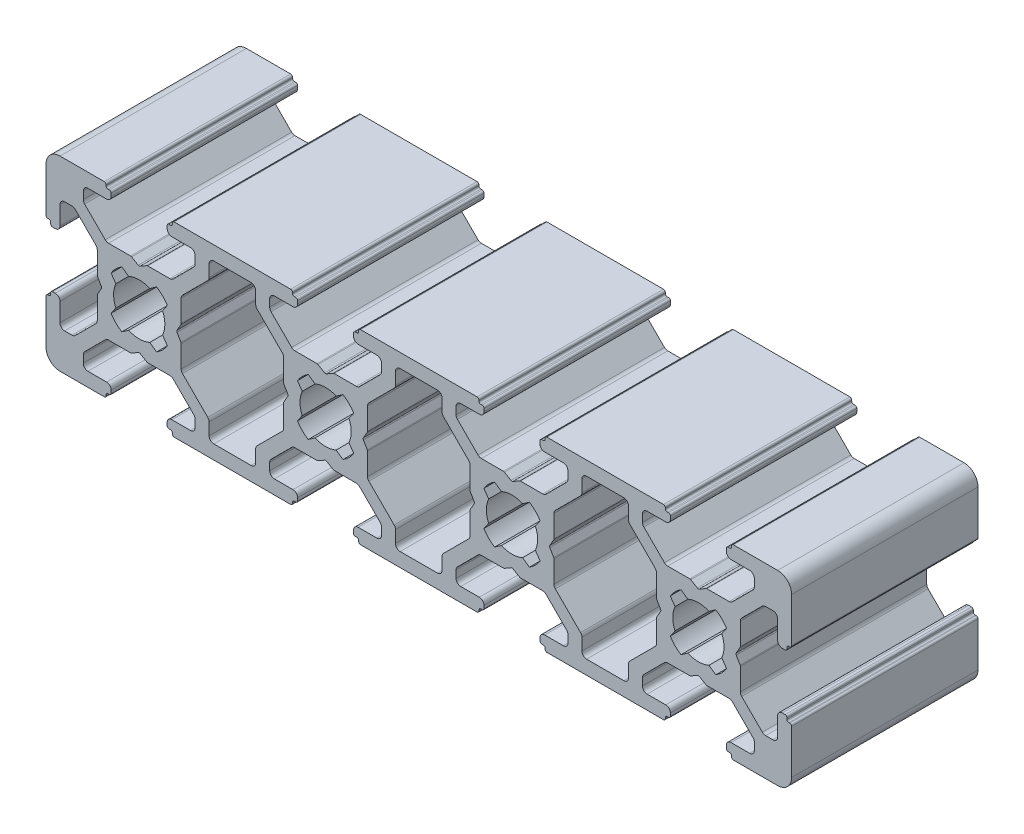
from build123d import *

# Parameters (mm, degrees)
EXTRUDE_1_DEPTH = 20


with BuildPart() as part:
    # Эскиз1 → Бобышка-Вытянуть1 (new body)
    with BuildSketch(Plane.XY):
        with BuildLine():
            Line((-13.645430713, 4.646446609), (-15.853553391, 6.854569287))
            ThreePointArc((-15.853553391, 6.854569287), (-15.961939766, 7.016780961), (-16, 7.208122677))
            Line((-16, 7.208122677), (-16, 8))
            ThreePointArc((-16, 8), (-15.853553391, 8.353553391), (-15.5, 8.5))
            Line((-15.5, 8.5), (-13.5, 8.5))
            ThreePointArc((-13.5, 8.5), (-13.146446609, 8.646446609), (-13, 9))
            Line((-13, 9), (-13, 9.3))
            ThreePointArc((-13, 9.3), (-13.058578644, 9.441421356), (-13.2, 9.5))
            Line((-13.2, 9.5), (-13.35, 9.5))
            ThreePointArc((-13.35, 9.5), (-13.491421356, 9.558578644), (-13.55, 9.7))
            Line((-13.55, 9.7), (-13.55, 9.8))
            ThreePointArc((-13.55, 9.8), (-13.608578644, 9.941421356), (-13.75, 10))
            Line((-13.75, 10), (-18.5, 10))
            ThreePointArc((-18.5, 10), (-19.560660172, 9.560660172), (-20, 8.5))
            Line((-20, 8.5), (-20, 3.75))
            ThreePointArc((-20, 3.75), (-19.941421356, 3.608578644), (-19.8, 3.55))
            Line((-19.8, 3.55), (-19.7, 3.55))
            ThreePointArc((-19.7, 3.55), (-19.558578644, 3.491421356), (-19.5, 3.35))
            Line((-19.5, 3.35), (-19.5, 3.2))
            ThreePointArc((-19.5, 3.2), (-19.441421356, 3.058578644), (-19.3, 3))
            Line((-19.3, 3), (-19, 3))
            ThreePointArc((-19, 3), (-18.646446609, 3.146446609), (-18.5, 3.5))
            Line((-18.5, 3.5), (-18.5, 5.5))
            ThreePointArc((-18.5, 5.5), (-18.353553391, 5.853553391), (-18, 6))
            Line((-18, 6), (-17.208122677, 6))
            ThreePointArc((-17.208122677, 6), (-17.016780961, 5.961939766), (-16.854569287, 5.853553391))
            Line((-16.854569287, 5.853553391), (-14.646446609, 3.645430713))
            ThreePointArc((-14.646446609, 3.645430713), (-14.538060234, 3.483219039), (-14.5, 3.291877323))
            Line((-14.5, 3.291877323), (-14.5, 0.919615242))
            ThreePointArc((-14.5, 0.919615242), (-14.493185165, 0.867851433), (-14.473205081, 0.819615242))
            Line((-14.473205081, 0.819615242), (-14.057735027, 0.1))
            ThreePointArc((-14.057735027, 0.1), (-14.030940108, 0), (-14.057735027, -0.1))
            Line((-14.057735027, -0.1), (-14.473205081, -0.819615242))
            ThreePointArc((-14.473205081, -0.819615242), (-14.493185165, -0.867851433), (-14.5, -0.919615242))
            Line((-14.5, -0.919615242), (-14.5, -3.291877323))
            ThreePointArc((-14.5, -3.291877323), (-14.538060234, -3.483219039), (-14.646446609, -3.645430713))
            Line((-14.646446609, -3.645430713), (-16.854569287, -5.853553391))
            ThreePointArc((-16.854569287, -5.853553391), (-17.016780961, -5.961939766), (-17.208122677, -6))
            Line((-17.208122677, -6), (-18, -6))
            ThreePointArc((-18, -6), (-18.353553391, -5.853553391), (-18.5, -5.5))
            Line((-18.5, -5.5), (-18.5, -3.5))
            ThreePointArc((-18.5, -3.5), (-18.646446609, -3.146446609), (-19, -3))
            Line((-19, -3), (-19.3, -3))
            ThreePointArc((-19.3, -3), (-19.441421356, -3.058578644), (-19.5, -3.2))
            Line((-19.5, -3.2), (-19.5, -3.35))
            ThreePointArc((-19.5, -3.35), (-19.558578644, -3.491421356), (-19.7, -3.55))
            Line((-19.7, -3.55), (-19.8, -3.55))
            ThreePointArc((-19.8, -3.55), (-19.941421356, -3.608578644), (-20, -3.75))
            Line((-20, -3.75), (-20, -8.5))
            ThreePointArc((-20, -8.5), (-19.560660172, -9.560660172), (-18.5, -10))
            Line((-18.5, -10), (-13.75, -10))
            ThreePointArc((-13.75, -10), (-13.608578644, -9.941421356), (-13.55, -9.8))
            Line((-13.55, -9.8), (-13.55, -9.7))
            ThreePointArc((-13.55, -9.7), (-13.491421356, -9.558578644), (-13.35, -9.5))
            Line((-13.35, -9.5), (-13.2, -9.5))
            ThreePointArc((-13.2, -9.5), (-13.058578644, -9.441421356), (-13, -9.3))
            Line((-13, -9.3), (-13, -9))
            ThreePointArc((-13, -9), (-13.146446609, -8.646446609), (-13.5, -8.5))
            Line((-13.5, -8.5), (-15.5, -8.5))
            ThreePointArc((-15.5, -8.5), (-15.853553391, -8.353553391), (-16, -8))
            Line((-16, -8), (-16, -7.208122677))
            ThreePointArc((-16, -7.208122677), (-15.961939766, -7.016780961), (-15.853553391, -6.854569287))
            Line((-15.853553391, -6.854569287), (-13.645430713, -4.646446609))
            ThreePointArc((-13.645430713, -4.646446609), (-13.483219039, -4.538060234), (-13.291877323, -4.5))
            Line((-13.291877323, -4.5), (-10.919615242, -4.5))
            ThreePointArc((-10.919615242, -4.5), (-10.867851433, -4.493185165), (-10.819615242, -4.473205081))
            Line((-10.819615242, -4.473205081), (-10.1, -4.057735027))
            ThreePointArc((-10.1, -4.057735027), (-10, -4.030940108), (-9.9, -4.057735027))
            Line((-9.9, -4.057735027), (-9.180384758, -4.473205081))
            ThreePointArc((-9.180384758, -4.473205081), (-9.132148567, -4.493185165), (-9.080384758, -4.5))
            Line((-9.080384758, -4.5), (-6.708122677, -4.5))
            ThreePointArc((-6.708122677, -4.5), (-6.516780961, -4.538060234), (-6.354569287, -4.646446609))
            Line((-6.354569287, -4.646446609), (-4.146446609, -6.854569287))
            ThreePointArc((-4.146446609, -6.854569287), (-4.038060234, -7.016780961), (-4, -7.208122677))
            Line((-4, -7.208122677), (-4, -8))
            ThreePointArc((-4, -8), (-4.146446609, -8.353553391), (-4.5, -8.5))
            Line((-4.5, -8.5), (-6.5, -8.5))
            ThreePointArc((-6.5, -8.5), (-6.853553391, -8.646446609), (-7, -9))
            Line((-7, -9), (-7, -9.3))
            ThreePointArc((-7, -9.3), (-6.941421356, -9.441421356), (-6.8, -9.5))
            Line((-6.8, -9.5), (-6.65, -9.5))
            ThreePointArc((-6.65, -9.5), (-6.508578644, -9.558578644), (-6.45, -9.7))
            Line((-6.45, -9.7), (-6.45, -9.8))
            ThreePointArc((-6.45, -9.8), (-6.391421356, -9.941421356), (-6.25, -10))
            Line((-6.25, -10), (6.25, -10))
            ThreePointArc((6.25, -10), (6.391421356, -9.941421356), (6.45, -9.8))
            Line((6.45, -9.8), (6.45, -9.7))
            ThreePointArc((6.45, -9.7), (6.508578644, -9.558578644), (6.65, -9.5))
            Line((6.65, -9.5), (6.8, -9.5))
            ThreePointArc((6.8, -9.5), (6.941421356, -9.441421356), (7, -9.3))
            Line((7, -9.3), (7, -9))
            ThreePointArc((7, -9), (6.853553391, -8.646446609), (6.5, -8.5))
            Line((6.5, -8.5), (4.5, -8.5))
            ThreePointArc((4.5, -8.5), (4.146446609, -8.353553391), (4, -8))
            Line((4, -8), (4, -7.208122677))
            ThreePointArc((4, -7.208122677), (4.038060234, -7.016780961), (4.146446609, -6.854569287))
            Line((4.146446609, -6.854569287), (6.354569287, -4.646446609))
            ThreePointArc((6.354569287, -4.646446609), (6.516780961, -4.538060234), (6.708122677, -4.5))
            Line((6.708122677, -4.5), (9.080384758, -4.5))
            ThreePointArc((9.080384758, -4.5), (9.132148567, -4.493185165), (9.180384758, -4.473205081))
            Line((9.180384758, -4.473205081), (9.9, -4.057735027))
            ThreePointArc((9.9, -4.057735027), (10, -4.030940108), (10.1, -4.057735027))
            Line((10.1, -4.057735027), (10.819615242, -4.473205081))
            ThreePointArc((10.819615242, -4.473205081), (10.867851433, -4.493185165), (10.919615242, -4.5))
            Line((10.919615242, -4.5), (13.291877323, -4.5))
            ThreePointArc((13.291877323, -4.5), (13.483219039, -4.538060234), (13.645430713, -4.646446609))
            Line((13.645430713, -4.646446609), (15.853553391, -6.854569287))
            ThreePointArc((15.853553391, -6.854569287), (15.961939766, -7.016780961), (16, -7.208122677))
            Line((16, -7.208122677), (16, -8))
            ThreePointArc((16, -8), (15.853553391, -8.353553391), (15.5, -8.5))
            Line((15.5, -8.5), (13.5, -8.5))
            ThreePointArc((13.5, -8.5), (13.146446609, -8.646446609), (13, -9))
            Line((13, -9), (13, -9.3))
            ThreePointArc((13, -9.3), (13.058578644, -9.441421356), (13.2, -9.5))
            Line((13.2, -9.5), (13.35, -9.5))
            ThreePointArc((13.35, -9.5), (13.491421356, -9.558578644), (13.55, -9.7))
            Line((13.55, -9.7), (13.55, -9.8))
            ThreePointArc((13.55, -9.8), (13.608578644, -9.941421356), (13.75, -10))
            Line((13.75, -10), (26.25, -10))
            ThreePointArc((26.25, -10), (26.391421356, -9.941421356), (26.45, -9.8))
            Line((26.45, -9.8), (26.45, -9.7))
            ThreePointArc((26.45, -9.7), (26.508578644, -9.558578644), (26.65, -9.5))
            Line((26.65, -9.5), (26.8, -9.5))
            ThreePointArc((26.8, -9.5), (26.941421356, -9.441421356), (27, -9.3))
            Line((27, -9.3), (27, -9))
            ThreePointArc((27, -9), (26.853553391, -8.646446609), (26.5, -8.5))
            Line((26.5, -8.5), (24.5, -8.5))
            ThreePointArc((24.5, -8.5), (24.146446609, -8.353553391), (24, -8))
            Line((24, -8), (24, -7.208122677))
            ThreePointArc((24, -7.208122677), (24.038060234, -7.016780961), (24.146446609, -6.854569287))
            Line((24.146446609, -6.854569287), (26.354569287, -4.646446609))
            ThreePointArc((26.354569287, -4.646446609), (26.516780961, -4.538060234), (26.708122677, -4.5))
            Line((26.708122677, -4.5), (29.080384758, -4.5))
            ThreePointArc((29.080384758, -4.5), (29.132148567, -4.493185165), (29.180384758, -4.473205081))
            Line((29.180384758, -4.473205081), (29.9, -4.057735027))
            ThreePointArc((29.9, -4.057735027), (30, -4.030940108), (30.1, -4.057735027))
            Line((30.1, -4.057735027), (30.819615242, -4.473205081))
            ThreePointArc((30.819615242, -4.473205081), (30.867851433, -4.493185165), (30.919615242, -4.5))
            Line((30.919615242, -4.5), (33.291877323, -4.5))
            ThreePointArc((33.291877323, -4.5), (33.483219039, -4.538060234), (33.645430713, -4.646446609))
            Line((33.645430713, -4.646446609), (35.853553391, -6.854569287))
            ThreePointArc((35.853553391, -6.854569287), (35.961939766, -7.016780961), (36, -7.208122677))
            Line((36, -7.208122677), (36, -8))
            ThreePointArc((36, -8), (35.853553391, -8.353553391), (35.5, -8.5))
            Line((35.5, -8.5), (33.5, -8.5))
            ThreePointArc((33.5, -8.5), (33.146446609, -8.646446609), (33, -9))
            Line((33, -9), (33, -9.3))
            ThreePointArc((33, -9.3), (33.058578644, -9.441421356), (33.2, -9.5))
            Line((33.2, -9.5), (33.35, -9.5))
            ThreePointArc((33.35, -9.5), (33.491421356, -9.558578644), (33.55, -9.7))
            Line((33.55, -9.7), (33.55, -9.8))
            ThreePointArc((33.55, -9.8), (33.608578644, -9.941421356), (33.75, -10))
            Line((33.75, -10), (46.25, -10))
            ThreePointArc((46.25, -10), (46.391421356, -9.941421356), (46.45, -9.8))
            Line((46.45, -9.8), (46.45, -9.7))
            ThreePointArc((46.45, -9.7), (46.508578644, -9.558578644), (46.65, -9.5))
            Line((46.65, -9.5), (46.8, -9.5))
            ThreePointArc((46.8, -9.5), (46.941421356, -9.441421356), (47, -9.3))
            Line((47, -9.3), (47, -9))
            ThreePointArc((47, -9), (46.853553391, -8.646446609), (46.5, -8.5))
            Line((46.5, -8.5), (44.5, -8.5))
            ThreePointArc((44.5, -8.5), (44.146446609, -8.353553391), (44, -8))
            Line((44, -8), (44, -7.208122677))
            ThreePointArc((44, -7.208122677), (44.038060234, -7.016780961), (44.146446609, -6.854569287))
            Line((44.146446609, -6.854569287), (46.354569287, -4.646446609))
            ThreePointArc((46.354569287, -4.646446609), (46.516780961, -4.538060234), (46.708122677, -4.5))
            Line((46.708122677, -4.5), (49.080384758, -4.5))
            ThreePointArc((49.080384758, -4.5), (49.132148567, -4.493185165), (49.180384758, -4.473205081))
            Line((49.180384758, -4.473205081), (49.9, -4.057735027))
            ThreePointArc((49.9, -4.057735027), (50, -4.030940108), (50.1, -4.057735027))
            Line((50.1, -4.057735027), (50.819615242, -4.473205081))
            ThreePointArc((50.819615242, -4.473205081), (50.867851433, -4.493185165), (50.919615242, -4.5))
            Line((50.919615242, -4.5), (53.291877323, -4.5))
            ThreePointArc((53.291877323, -4.5), (53.483219039, -4.538060234), (53.645430713, -4.646446609))
            Line((53.645430713, -4.646446609), (55.853553391, -6.854569287))
            ThreePointArc((55.853553391, -6.854569287), (55.961939766, -7.016780961), (56, -7.208122677))
            Line((56, -7.208122677), (56, -8))
            ThreePointArc((56, -8), (55.853553391, -8.353553391), (55.5, -8.5))
            Line((55.5, -8.5), (53.5, -8.5))
            ThreePointArc((53.5, -8.5), (53.146446609, -8.646446609), (53, -9))
            Line((53, -9), (53, -9.3))
            ThreePointArc((53, -9.3), (53.058578644, -9.441421356), (53.2, -9.5))
            Line((53.2, -9.5), (53.35, -9.5))
            ThreePointArc((53.35, -9.5), (53.491421356, -9.558578644), (53.55, -9.7))
            Line((53.55, -9.7), (53.55, -9.8))
            ThreePointArc((53.55, -9.8), (53.608578644, -9.941421356), (53.75, -10))
            Line((53.75, -10), (58.5, -10))
            ThreePointArc((58.5, -10), (59.560660172, -9.560660172), (60, -8.5))
            Line((60, -8.5), (60, -3.75))
            ThreePointArc((60, -3.75), (59.941421356, -3.608578644), (59.8, -3.55))
            Line((59.8, -3.55), (59.7, -3.55))
            ThreePointArc((59.7, -3.55), (59.558578644, -3.491421356), (59.5, -3.35))
            Line((59.5, -3.35), (59.5, -3.2))
            ThreePointArc((59.5, -3.2), (59.441421356, -3.058578644), (59.3, -3))
            Line((59.3, -3), (59, -3))
            ThreePointArc((59, -3), (58.646446609, -3.146446609), (58.5, -3.5))
            Line((58.5, -3.5), (58.5, -5.5))
            ThreePointArc((58.5, -5.5), (58.353553391, -5.853553391), (58, -6))
            Line((58, -6), (57.208122677, -6))
            ThreePointArc((57.208122677, -6), (57.016780961, -5.961939766), (56.854569287, -5.853553391))
            Line((56.854569287, -5.853553391), (54.646446609, -3.645430713))
            ThreePointArc((54.646446609, -3.645430713), (54.538060234, -3.483219039), (54.5, -3.291877323))
            Line((54.5, -3.291877323), (54.5, -0.919615242))
            ThreePointArc((54.5, -0.919615242), (54.493185165, -0.867851433), (54.473205081, -0.819615242))
            Line((54.473205081, -0.819615242), (54.057735027, -0.1))
            ThreePointArc((54.057735027, -0.1), (54.030940108, 0), (54.057735027, 0.1))
            Line((54.057735027, 0.1), (54.473205081, 0.819615242))
            ThreePointArc((54.473205081, 0.819615242), (54.493185165, 0.867851433), (54.5, 0.919615242))
            Line((54.5, 0.919615242), (54.5, 3.291877323))
            ThreePointArc((54.5, 3.291877323), (54.538060234, 3.483219039), (54.646446609, 3.645430713))
            Line((54.646446609, 3.645430713), (56.854569287, 5.853553391))
            ThreePointArc((56.854569287, 5.853553391), (57.016780961, 5.961939766), (57.208122677, 6))
            Line((57.208122677, 6), (58, 6))
            ThreePointArc((58, 6), (58.353553391, 5.853553391), (58.5, 5.5))
            Line((58.5, 5.5), (58.5, 3.5))
            ThreePointArc((58.5, 3.5), (58.646446609, 3.146446609), (59, 3))
            Line((59, 3), (59.3, 3))
            ThreePointArc((59.3, 3), (59.441421356, 3.058578644), (59.5, 3.2))
            Line((59.5, 3.2), (59.5, 3.35))
            ThreePointArc((59.5, 3.35), (59.558578644, 3.491421356), (59.7, 3.55))
            Line((59.7, 3.55), (59.8, 3.55))
            ThreePointArc((59.8, 3.55), (59.941421356, 3.608578644), (60, 3.75))
            Line((60, 3.75), (60, 8.5))
            ThreePointArc((60, 8.5), (59.560660172, 9.560660172), (58.5, 10))
            Line((58.5, 10), (53.75, 10))
            ThreePointArc((53.75, 10), (53.608578644, 9.941421356), (53.55, 9.8))
            Line((53.55, 9.8), (53.55, 9.7))
            ThreePointArc((53.55, 9.7), (53.491421356, 9.558578644), (53.35, 9.5))
            Line((53.35, 9.5), (53.2, 9.5))
            ThreePointArc((53.2, 9.5), (53.058578644, 9.441421356), (53, 9.3))
            Line((53, 9.3), (53, 9))
            ThreePointArc((53, 9), (53.146446609, 8.646446609), (53.5, 8.5))
            Line((53.5, 8.5), (55.5, 8.5))
            ThreePointArc((55.5, 8.5), (55.853553391, 8.353553391), (56, 8))
            Line((56, 8), (56, 7.208122677))
            ThreePointArc((56, 7.208122677), (55.961939766, 7.016780961), (55.853553391, 6.854569287))
            Line((55.853553391, 6.854569287), (53.645430713, 4.646446609))
            ThreePointArc((53.645430713, 4.646446609), (53.483219039, 4.538060234), (53.291877323, 4.5))
            Line((53.291877323, 4.5), (50.919615242, 4.5))
            ThreePointArc((50.919615242, 4.5), (50.867851433, 4.493185165), (50.819615242, 4.473205081))
            Line((50.819615242, 4.473205081), (50.1, 4.057735027))
            ThreePointArc((50.1, 4.057735027), (50, 4.030940108), (49.9, 4.057735027))
            Line((49.9, 4.057735027), (49.180384758, 4.473205081))
            ThreePointArc((49.180384758, 4.473205081), (49.132148567, 4.493185165), (49.080384758, 4.5))
            Line((49.080384758, 4.5), (46.708122677, 4.5))
            ThreePointArc((46.708122677, 4.5), (46.516780961, 4.538060234), (46.354569287, 4.646446609))
            Line((46.354569287, 4.646446609), (44.146446609, 6.854569287))
            ThreePointArc((44.146446609, 6.854569287), (44.038060234, 7.016780961), (44, 7.208122677))
            Line((44, 7.208122677), (44, 8))
            ThreePointArc((44, 8), (44.146446609, 8.353553391), (44.5, 8.5))
            Line((44.5, 8.5), (46.5, 8.5))
            ThreePointArc((46.5, 8.5), (46.853553391, 8.646446609), (47, 9))
            Line((47, 9), (47, 9.3))
            ThreePointArc((47, 9.3), (46.941421356, 9.441421356), (46.8, 9.5))
            Line((46.8, 9.5), (46.65, 9.5))
            ThreePointArc((46.65, 9.5), (46.508578644, 9.558578644), (46.45, 9.7))
            Line((46.45, 9.7), (46.45, 9.8))
            ThreePointArc((46.45, 9.8), (46.391421356, 9.941421356), (46.25, 10))
            Line((46.25, 10), (33.75, 10))
            ThreePointArc((33.75, 10), (33.608578644, 9.941421356), (33.55, 9.8))
            Line((33.55, 9.8), (33.55, 9.7))
            ThreePointArc((33.55, 9.7), (33.491421356, 9.558578644), (33.35, 9.5))
            Line((33.35, 9.5), (33.2, 9.5))
            ThreePointArc((33.2, 9.5), (33.058578644, 9.441421356), (33, 9.3))
            Line((33, 9.3), (33, 9))
            ThreePointArc((33, 9), (33.146446609, 8.646446609), (33.5, 8.5))
            Line((33.5, 8.5), (35.5, 8.5))
            ThreePointArc((35.5, 8.5), (35.853553391, 8.353553391), (36, 8))
            Line((36, 8), (36, 7.208122677))
            ThreePointArc((36, 7.208122677), (35.961939766, 7.016780961), (35.853553391, 6.854569287))
            Line((35.853553391, 6.854569287), (33.645430713, 4.646446609))
            ThreePointArc((33.645430713, 4.646446609), (33.483219039, 4.538060234), (33.291877323, 4.5))
            Line((33.291877323, 4.5), (30.919615242, 4.5))
            ThreePointArc((30.919615242, 4.5), (30.867851433, 4.493185165), (30.819615242, 4.473205081))
            Line((30.819615242, 4.473205081), (30.1, 4.057735027))
            ThreePointArc((30.1, 4.057735027), (30, 4.030940108), (29.9, 4.057735027))
            Line((29.9, 4.057735027), (29.180384758, 4.473205081))
            ThreePointArc((29.180384758, 4.473205081), (29.132148567, 4.493185165), (29.080384758, 4.5))
            Line((29.080384758, 4.5), (26.708122677, 4.5))
            ThreePointArc((26.708122677, 4.5), (26.516780961, 4.538060234), (26.354569287, 4.646446609))
            Line((26.354569287, 4.646446609), (24.146446609, 6.854569287))
            ThreePointArc((24.146446609, 6.854569287), (24.038060234, 7.016780961), (24, 7.208122677))
            Line((24, 7.208122677), (24, 8))
            ThreePointArc((24, 8), (24.146446609, 8.353553391), (24.5, 8.5))
            Line((24.5, 8.5), (26.5, 8.5))
            ThreePointArc((26.5, 8.5), (26.853553391, 8.646446609), (27, 9))
            Line((27, 9), (27, 9.3))
            ThreePointArc((27, 9.3), (26.941421356, 9.441421356), (26.8, 9.5))
            Line((26.8, 9.5), (26.65, 9.5))
            ThreePointArc((26.65, 9.5), (26.508578644, 9.558578644), (26.45, 9.7))
            Line((26.45, 9.7), (26.45, 9.8))
            ThreePointArc((26.45, 9.8), (26.391421356, 9.941421356), (26.25, 10))
            Line((26.25, 10), (13.75, 10))
            ThreePointArc((13.75, 10), (13.608578644, 9.941421356), (13.55, 9.8))
            Line((13.55, 9.8), (13.55, 9.7))
            ThreePointArc((13.55, 9.7), (13.491421356, 9.558578644), (13.35, 9.5))
            Line((13.35, 9.5), (13.2, 9.5))
            ThreePointArc((13.2, 9.5), (13.058578644, 9.441421356), (13, 9.3))
            Line((13, 9.3), (13, 9))
            ThreePointArc((13, 9), (13.146446609, 8.646446609), (13.5, 8.5))
            Line((13.5, 8.5), (15.5, 8.5))
            ThreePointArc((15.5, 8.5), (15.853553391, 8.353553391), (16, 8))
            Line((16, 8), (16, 7.208122677))
            ThreePointArc((16, 7.208122677), (15.961939766, 7.016780961), (15.853553391, 6.854569287))
            Line((15.853553391, 6.854569287), (13.645430713, 4.646446609))
            ThreePointArc((13.645430713, 4.646446609), (13.483219039, 4.538060234), (13.291877323, 4.5))
            Line((13.291877323, 4.5), (10.919615242, 4.5))
            ThreePointArc((10.919615242, 4.5), (10.867851433, 4.493185165), (10.819615242, 4.473205081))
            Line((10.819615242, 4.473205081), (10.1, 4.057735027))
            ThreePointArc((10.1, 4.057735027), (10, 4.030940108), (9.9, 4.057735027))
            Line((9.9, 4.057735027), (9.180384758, 4.473205081))
            ThreePointArc((9.180384758, 4.473205081), (9.132148567, 4.493185165), (9.080384758, 4.5))
            Line((9.080384758, 4.5), (6.708122677, 4.5))
            ThreePointArc((6.708122677, 4.5), (6.516780961, 4.538060234), (6.354569287, 4.646446609))
            Line((6.354569287, 4.646446609), (4.146446609, 6.854569287))
            ThreePointArc((4.146446609, 6.854569287), (4.038060234, 7.016780961), (4, 7.208122677))
            Line((4, 7.208122677), (4, 8))
            ThreePointArc((4, 8), (4.146446609, 8.353553391), (4.5, 8.5))
            Line((4.5, 8.5), (6.5, 8.5))
            ThreePointArc((6.5, 8.5), (6.853553391, 8.646446609), (7, 9))
            Line((7, 9), (7, 9.3))
            ThreePointArc((7, 9.3), (6.941421356, 9.441421356), (6.8, 9.5))
            Line((6.8, 9.5), (6.65, 9.5))
            ThreePointArc((6.65, 9.5), (6.508578644, 9.558578644), (6.45, 9.7))
            Line((6.45, 9.7), (6.45, 9.8))
            ThreePointArc((6.45, 9.8), (6.391421356, 9.941421356), (6.25, 10))
            Line((6.25, 10), (-6.25, 10))
            ThreePointArc((-6.25, 10), (-6.391421356, 9.941421356), (-6.45, 9.8))
            Line((-6.45, 9.8), (-6.45, 9.7))
            ThreePointArc((-6.45, 9.7), (-6.508578644, 9.558578644), (-6.65, 9.5))
            Line((-6.65, 9.5), (-6.8, 9.5))
            ThreePointArc((-6.8, 9.5), (-6.941421356, 9.441421356), (-7, 9.3))
            Line((-7, 9.3), (-7, 9))
            ThreePointArc((-7, 9), (-6.853553391, 8.646446609), (-6.5, 8.5))
            Line((-6.5, 8.5), (-4.5, 8.5))
            ThreePointArc((-4.5, 8.5), (-4.146446609, 8.353553391), (-4, 8))
            Line((-4, 8), (-4, 7.208122677))
            ThreePointArc((-4, 7.208122677), (-4.038060234, 7.016780961), (-4.146446609, 6.854569287))
            Line((-4.146446609, 6.854569287), (-6.354569287, 4.646446609))
            ThreePointArc((-6.354569287, 4.646446609), (-6.516780961, 4.538060234), (-6.708122677, 4.5))
            Line((-6.708122677, 4.5), (-9.080384758, 4.5))
            ThreePointArc((-9.080384758, 4.5), (-9.132148567, 4.493185165), (-9.180384758, 4.473205081))
            Line((-9.180384758, 4.473205081), (-9.9, 4.057735027))
            ThreePointArc((-9.9, 4.057735027), (-10, 4.030940108), (-10.1, 4.057735027))
            Line((-10.1, 4.057735027), (-10.819615242, 4.473205081))
            ThreePointArc((-10.819615242, 4.473205081), (-10.867851433, 4.493185165), (-10.919615242, 4.5))
            Line((-10.919615242, 4.5), (-13.291877323, 4.5))
            ThreePointArc((-13.291877323, 4.5), (-13.483219039, 4.538060234), (-13.645430713, 4.646446609))
        make_face()
        with BuildLine():
            Line((3.145430713, -5.853553391), (2.646446609, -6.352537495))
            ThreePointArc((2.646446609, -6.352537495), (2.538060234, -6.514749169), (2.5, -6.706090885))
            Line((2.5, -6.706090885), (2.5, -8))
            ThreePointArc((2.5, -8), (2.353553391, -8.353553391), (2, -8.5))
            Line((2, -8.5), (-2, -8.5))
            ThreePointArc((-2, -8.5), (-2.353553391, -8.353553391), (-2.5, -8))
            Line((-2.5, -8), (-2.5, -6.706090885))
            ThreePointArc((-2.5, -6.706090885), (-2.538060234, -6.514749169), (-2.646446609, -6.352537495))
            Line((-2.646446609, -6.352537495), (-3.145430713, -5.853553391))
            Line((-3.145430713, -5.853553391), (-5.353553391, -3.645430713))
            ThreePointArc((-5.353553391, -3.645430713), (-5.461939766, -3.483219039), (-5.5, -3.291877323))
            Line((-5.5, -3.291877323), (-5.5, -0.919615242))
            ThreePointArc((-5.5, -0.919615242), (-5.506814835, -0.867851433), (-5.526794919, -0.819615242))
            Line((-5.526794919, -0.819615242), (-5.942264973, -0.1))
            ThreePointArc((-5.942264973, -0.1), (-5.969059892, 0), (-5.942264973, 0.1))
            Line((-5.942264973, 0.1), (-5.526794919, 0.819615242))
            ThreePointArc((-5.526794919, 0.819615242), (-5.506814835, 0.867851433), (-5.5, 0.919615242))
            Line((-5.5, 0.919615242), (-5.5, 3.291877323))
            ThreePointArc((-5.5, 3.291877323), (-5.461939766, 3.483219039), (-5.353553391, 3.645430713))
            Line((-5.353553391, 3.645430713), (-3.145430713, 5.853553391))
            Line((-3.145430713, 5.853553391), (-2.646446609, 6.352537495))
            ThreePointArc((-2.646446609, 6.352537495), (-2.538060234, 6.514749169), (-2.5, 6.706090885))
            Line((-2.5, 6.706090885), (-2.5, 8))
            ThreePointArc((-2.5, 8), (-2.353553391, 8.353553391), (-2, 8.5))
            Line((-2, 8.5), (2, 8.5))
            ThreePointArc((2, 8.5), (2.353553391, 8.353553391), (2.5, 8))
            Line((2.5, 8), (2.5, 6.706090885))
            ThreePointArc((2.5, 6.706090885), (2.538060234, 6.514749169), (2.646446609, 6.352537495))
            Line((2.646446609, 6.352537495), (3.145430713, 5.853553391))
            Line((3.145430713, 5.853553391), (5.353553391, 3.645430713))
            ThreePointArc((5.353553391, 3.645430713), (5.461939766, 3.483219039), (5.5, 3.291877323))
            Line((5.5, 3.291877323), (5.5, 0.919615242))
            ThreePointArc((5.5, 0.919615242), (5.506814835, 0.867851433), (5.526794919, 0.819615242))
            Line((5.526794919, 0.819615242), (5.942264973, 0.1))
            ThreePointArc((5.942264973, 0.1), (5.969059892, 0), (5.942264973, -0.1))
            Line((5.942264973, -0.1), (5.526794919, -0.819615242))
            ThreePointArc((5.526794919, -0.819615242), (5.506814835, -0.867851433), (5.5, -0.919615242))
            Line((5.5, -0.919615242), (5.5, -3.291877323))
            ThreePointArc((5.5, -3.291877323), (5.461939766, -3.483219039), (5.353553391, -3.645430713))
            Line((5.353553391, -3.645430713), (3.145430713, -5.853553391))
        make_face(mode=Mode.SUBTRACT)
        with BuildLine():
            Line((-13.020442772, 1.865321812), (-12.506504586, 1.131342017))
            ThreePointArc((-12.506504586, 1.131342017), (-12.75, 0), (-12.506504586, -1.131342017))
            Line((-12.506504586, -1.131342017), (-13.020442772, -1.865321812))
            ThreePointArc((-13.020442772, -1.865321812), (-12.510229073, -2.510229073), (-11.865321812, -3.020442772))
            Line((-11.865321812, -3.020442772), (-11.131342017, -2.506504586))
            ThreePointArc((-11.131342017, -2.506504586), (-10, -2.75), (-8.868657983, -2.506504586))
            Line((-8.868657983, -2.506504586), (-8.134678188, -3.020442772))
            ThreePointArc((-8.134678188, -3.020442772), (-7.489770927, -2.510229073), (-6.979557228, -1.865321812))
            Line((-6.979557228, -1.865321812), (-7.493495414, -1.131342017))
            ThreePointArc((-7.493495414, -1.131342017), (-7.25, 0), (-7.493495414, 1.131342017))
            Line((-7.493495414, 1.131342017), (-6.979557228, 1.865321812))
            ThreePointArc((-6.979557228, 1.865321812), (-7.489770927, 2.510229073), (-8.134678188, 3.020442772))
            Line((-8.134678188, 3.020442772), (-8.868657983, 2.506504586))
            ThreePointArc((-8.868657983, 2.506504586), (-10, 2.75), (-11.131342017, 2.506504586))
            Line((-11.131342017, 2.506504586), (-11.865321812, 3.020442772))
            ThreePointArc((-11.865321812, 3.020442772), (-12.510229073, 2.510229073), (-13.020442772, 1.865321812))
        make_face(mode=Mode.SUBTRACT)
        with BuildLine():
            Line((14.5, -0.919615242), (14.5, -3.291877323))
            ThreePointArc((14.5, -3.291877323), (14.538060234, -3.483219039), (14.646446609, -3.645430713))
            Line((14.646446609, -3.645430713), (16.854569287, -5.853553391))
            Line((16.854569287, -5.853553391), (17.353553391, -6.352537495))
            ThreePointArc((17.353553391, -6.352537495), (17.461939766, -6.514749169), (17.5, -6.706090885))
            Line((17.5, -6.706090885), (17.5, -8))
            ThreePointArc((17.5, -8), (17.646446609, -8.353553391), (18, -8.5))
            Line((18, -8.5), (22, -8.5))
            ThreePointArc((22, -8.5), (22.353553391, -8.353553391), (22.5, -8))
            Line((22.5, -8), (22.5, -6.706090885))
            ThreePointArc((22.5, -6.706090885), (22.538060234, -6.514749169), (22.646446609, -6.352537495))
            Line((22.646446609, -6.352537495), (23.145430713, -5.853553391))
            Line((23.145430713, -5.853553391), (25.353553391, -3.645430713))
            ThreePointArc((25.353553391, -3.645430713), (25.461939766, -3.483219039), (25.5, -3.291877323))
            Line((25.5, -3.291877323), (25.5, -0.919615242))
            ThreePointArc((25.5, -0.919615242), (25.506814835, -0.867851433), (25.526794919, -0.819615242))
            Line((25.526794919, -0.819615242), (25.942264973, -0.1))
            ThreePointArc((25.942264973, -0.1), (25.969059892, 0), (25.942264973, 0.1))
            Line((25.942264973, 0.1), (25.526794919, 0.819615242))
            ThreePointArc((25.526794919, 0.819615242), (25.506814835, 0.867851433), (25.5, 0.919615242))
            Line((25.5, 0.919615242), (25.5, 3.291877323))
            ThreePointArc((25.5, 3.291877323), (25.461939766, 3.483219039), (25.353553391, 3.645430713))
            Line((25.353553391, 3.645430713), (23.145430713, 5.853553391))
            Line((23.145430713, 5.853553391), (22.646446609, 6.352537495))
            ThreePointArc((22.646446609, 6.352537495), (22.538060234, 6.514749169), (22.5, 6.706090885))
            Line((22.5, 6.706090885), (22.5, 8))
            ThreePointArc((22.5, 8), (22.353553391, 8.353553391), (22, 8.5))
            Line((22, 8.5), (18, 8.5))
            ThreePointArc((18, 8.5), (17.646446609, 8.353553391), (17.5, 8))
            Line((17.5, 8), (17.5, 6.706090885))
            ThreePointArc((17.5, 6.706090885), (17.461939766, 6.514749169), (17.353553391, 6.352537495))
            Line((17.353553391, 6.352537495), (16.854569287, 5.853553391))
            Line((16.854569287, 5.853553391), (14.646446609, 3.645430713))
            ThreePointArc((14.646446609, 3.645430713), (14.538060234, 3.483219039), (14.5, 3.291877323))
            Line((14.5, 3.291877323), (14.5, 0.919615242))
            ThreePointArc((14.5, 0.919615242), (14.493185165, 0.867851433), (14.473205081, 0.819615242))
            Line((14.473205081, 0.819615242), (14.057735027, 0.1))
            ThreePointArc((14.057735027, 0.1), (14.030940108, 0), (14.057735027, -0.1))
            Line((14.057735027, -0.1), (14.473205081, -0.819615242))
            ThreePointArc((14.473205081, -0.819615242), (14.493185165, -0.867851433), (14.5, -0.919615242))
        make_face(mode=Mode.SUBTRACT)
        with BuildLine():
            Line((13.020442772, -1.865321812), (12.506504586, -1.131342017))
            ThreePointArc((12.506504586, -1.131342017), (12.75, 0), (12.506504586, 1.131342017))
            Line((12.506504586, 1.131342017), (13.020442772, 1.865321812))
            ThreePointArc((13.020442772, 1.865321812), (12.510229073, 2.510229073), (11.865321812, 3.020442772))
            Line((11.865321812, 3.020442772), (11.131342017, 2.506504586))
            ThreePointArc((11.131342017, 2.506504586), (10, 2.75), (8.868657983, 2.506504586))
            Line((8.868657983, 2.506504586), (8.134678188, 3.020442772))
            ThreePointArc((8.134678188, 3.020442772), (7.489770927, 2.510229073), (6.979557228, 1.865321812))
            Line((6.979557228, 1.865321812), (7.493495414, 1.131342017))
            ThreePointArc((7.493495414, 1.131342017), (7.25, 0), (7.493495414, -1.131342017))
            Line((7.493495414, -1.131342017), (6.979557228, -1.865321812))
            ThreePointArc((6.979557228, -1.865321812), (7.489770927, -2.510229073), (8.134678188, -3.020442772))
            Line((8.134678188, -3.020442772), (8.868657983, -2.506504586))
            ThreePointArc((8.868657983, -2.506504586), (10, -2.75), (11.131342017, -2.506504586))
            Line((11.131342017, -2.506504586), (11.865321812, -3.020442772))
            ThreePointArc((11.865321812, -3.020442772), (12.510229073, -2.510229073), (13.020442772, -1.865321812))
        make_face(mode=Mode.SUBTRACT)
        with BuildLine():
            Line((26.979557228, -1.865321812), (27.493495414, -1.131342017))
            ThreePointArc((27.493495414, -1.131342017), (27.25, 0), (27.493495414, 1.131342017))
            Line((27.493495414, 1.131342017), (26.979557228, 1.865321812))
            ThreePointArc((26.979557228, 1.865321812), (27.489770927, 2.510229073), (28.134678188, 3.020442772))
            Line((28.134678188, 3.020442772), (28.868657983, 2.506504586))
            ThreePointArc((28.868657983, 2.506504586), (30, 2.75), (31.131342017, 2.506504586))
            Line((31.131342017, 2.506504586), (31.865321812, 3.020442772))
            ThreePointArc((31.865321812, 3.020442772), (32.510229073, 2.510229073), (33.020442772, 1.865321812))
            Line((33.020442772, 1.865321812), (32.506504586, 1.131342017))
            ThreePointArc((32.506504586, 1.131342017), (32.75, 0), (32.506504586, -1.131342017))
            Line((32.506504586, -1.131342017), (33.020442772, -1.865321812))
            ThreePointArc((33.020442772, -1.865321812), (32.510229073, -2.510229073), (31.865321812, -3.020442772))
            Line((31.865321812, -3.020442772), (31.131342017, -2.506504586))
            ThreePointArc((31.131342017, -2.506504586), (30, -2.75), (28.868657983, -2.506504586))
            Line((28.868657983, -2.506504586), (28.134678188, -3.020442772))
            ThreePointArc((28.134678188, -3.020442772), (27.489770927, -2.510229073), (26.979557228, -1.865321812))
        make_face(mode=Mode.SUBTRACT)
        with BuildLine():
            Line((34.5, -0.919615242), (34.5, -3.291877323))
            ThreePointArc((34.5, -3.291877323), (34.538060234, -3.483219039), (34.646446609, -3.645430713))
            Line((34.646446609, -3.645430713), (36.854569287, -5.853553391))
            Line((36.854569287, -5.853553391), (37.353553391, -6.352537495))
            ThreePointArc((37.353553391, -6.352537495), (37.461939766, -6.514749169), (37.5, -6.706090885))
            Line((37.5, -6.706090885), (37.5, -8))
            ThreePointArc((37.5, -8), (37.646446609, -8.353553391), (38, -8.5))
            Line((38, -8.5), (42, -8.5))
            ThreePointArc((42, -8.5), (42.353553391, -8.353553391), (42.5, -8))
            Line((42.5, -8), (42.5, -6.706090885))
            ThreePointArc((42.5, -6.706090885), (42.538060234, -6.514749169), (42.646446609, -6.352537495))
            Line((42.646446609, -6.352537495), (43.145430713, -5.853553391))
            Line((43.145430713, -5.853553391), (45.353553391, -3.645430713))
            ThreePointArc((45.353553391, -3.645430713), (45.461939766, -3.483219039), (45.5, -3.291877323))
            Line((45.5, -3.291877323), (45.5, -0.919615242))
            ThreePointArc((45.5, -0.919615242), (45.506814835, -0.867851433), (45.526794919, -0.819615242))
            Line((45.526794919, -0.819615242), (45.942264973, -0.1))
            ThreePointArc((45.942264973, -0.1), (45.969059892, 0), (45.942264973, 0.1))
            Line((45.942264973, 0.1), (45.526794919, 0.819615242))
            ThreePointArc((45.526794919, 0.819615242), (45.506814835, 0.867851433), (45.5, 0.919615242))
            Line((45.5, 0.919615242), (45.5, 3.291877323))
            ThreePointArc((45.5, 3.291877323), (45.461939766, 3.483219039), (45.353553391, 3.645430713))
            Line((45.353553391, 3.645430713), (43.145430713, 5.853553391))
            Line((43.145430713, 5.853553391), (42.646446609, 6.352537495))
            ThreePointArc((42.646446609, 6.352537495), (42.538060234, 6.514749169), (42.5, 6.706090885))
            Line((42.5, 6.706090885), (42.5, 8))
            ThreePointArc((42.5, 8), (42.353553391, 8.353553391), (42, 8.5))
            Line((42, 8.5), (38, 8.5))
            ThreePointArc((38, 8.5), (37.646446609, 8.353553391), (37.5, 8))
            Line((37.5, 8), (37.5, 6.706090885))
            ThreePointArc((37.5, 6.706090885), (37.461939766, 6.514749169), (37.353553391, 6.352537495))
            Line((37.353553391, 6.352537495), (36.854569287, 5.853553391))
            Line((36.854569287, 5.853553391), (34.646446609, 3.645430713))
            ThreePointArc((34.646446609, 3.645430713), (34.538060234, 3.483219039), (34.5, 3.291877323))
            Line((34.5, 3.291877323), (34.5, 0.919615242))
            ThreePointArc((34.5, 0.919615242), (34.493185165, 0.867851433), (34.473205081, 0.819615242))
            Line((34.473205081, 0.819615242), (34.057735027, 0.1))
            ThreePointArc((34.057735027, 0.1), (34.030940108, 0), (34.057735027, -0.1))
            Line((34.057735027, -0.1), (34.473205081, -0.819615242))
            ThreePointArc((34.473205081, -0.819615242), (34.493185165, -0.867851433), (34.5, -0.919615242))
        make_face(mode=Mode.SUBTRACT)
        with BuildLine():
            Line((53.020442772, -1.865321812), (52.506504586, -1.131342017))
            ThreePointArc((52.506504586, -1.131342017), (52.75, 0), (52.506504586, 1.131342017))
            Line((52.506504586, 1.131342017), (53.020442772, 1.865321812))
            ThreePointArc((53.020442772, 1.865321812), (52.510229073, 2.510229073), (51.865321812, 3.020442772))
            Line((51.865321812, 3.020442772), (51.131342017, 2.506504586))
            ThreePointArc((51.131342017, 2.506504586), (50, 2.75), (48.868657983, 2.506504586))
            Line((48.868657983, 2.506504586), (48.134678188, 3.020442772))
            ThreePointArc((48.134678188, 3.020442772), (47.489770927, 2.510229073), (46.979557228, 1.865321812))
            Line((46.979557228, 1.865321812), (47.493495414, 1.131342017))
            ThreePointArc((47.493495414, 1.131342017), (47.25, 0), (47.493495414, -1.131342017))
            Line((47.493495414, -1.131342017), (46.979557228, -1.865321812))
            ThreePointArc((46.979557228, -1.865321812), (47.489770927, -2.510229073), (48.134678188, -3.020442772))
            Line((48.134678188, -3.020442772), (48.868657983, -2.506504586))
            ThreePointArc((48.868657983, -2.506504586), (50, -2.75), (51.131342017, -2.506504586))
            Line((51.131342017, -2.506504586), (51.865321812, -3.020442772))
            ThreePointArc((51.865321812, -3.020442772), (52.510229073, -2.510229073), (53.020442772, -1.865321812))
        make_face(mode=Mode.SUBTRACT)
    extrude(amount=EXTRUDE_1_DEPTH)


solid = part.part
